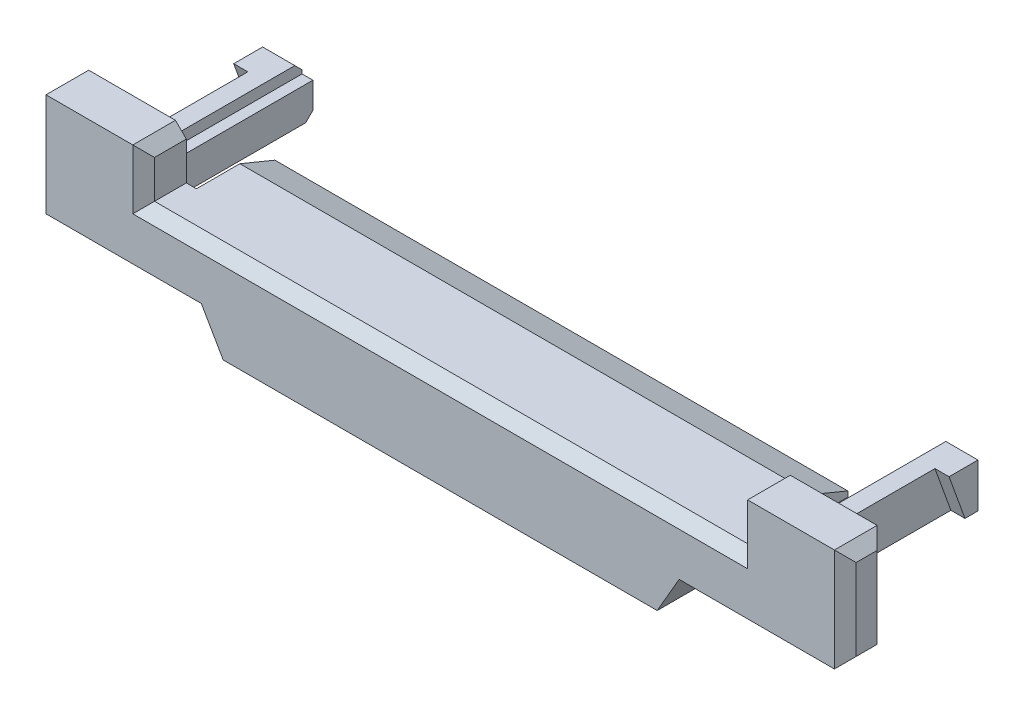
from build123d import *

# Parameters (mm, degrees)
BOSS_EXTRUDE1_DEPTH     = 1.18
SKETCH2_W               = 15.84
SKETCH2_H               = 2.17
BOSS_EXTRUDE2_DEPTH     = 0.55
CUT_EXTRUDE1_DEPTH      = 4.28
CUT_EXTRUDE1_DEPTH_BACK = 20.12
CHAMFER1_SIZE           = 0.3
CHAMFER2_SIZE           = 0.3
SKETCH4_W               = 1.19
SKETCH4_H               = 1.22
BOSS_EXTRUDE3_DEPTH     = 4
SKETCH5_W               = 0.3
SKETCH5_H               = 0.3
CUT_EXTRUDE2_DEPTH      = 4
CHAMFER3_SIZE           = 0.2
CUT_EXTRUDE3_DEPTH      = 0.39


with BuildPart() as part:
    # Sketch1 → Boss-Extrude1 (new body)
    with BuildSketch(Plane.XY):
        Polygon((-8.2, 0.6), (-8.2, 1.95), (-11.2, 1.95), (-11.2, -0.9), (-6.606217783, -0.9), (-6, -1.95), (6, -1.95), (6.606217783, -0.9), (11.2, -0.9), (11.2, 1.95), (8.2, 1.95), (8.2, 0.6), align=None)
    extrude(amount=BOSS_EXTRUDE1_DEPTH)

    # Sketch2 → Boss-Extrude2 (add)
    with BuildSketch(Plane(origin=(0, 0.6, 0), x_dir=(1, 0, 0), z_dir=(0, 1, 0))):
        with Locations((0, 1.085)):
            Rectangle(SKETCH2_W, SKETCH2_H)
    extrude(amount=-BOSS_EXTRUDE2_DEPTH)

    # Sketch3 → Cut-Extrude1 (cut, two sides)
    with BuildSketch(Plane.ZY.offset(7.92)) as cut_extrude1_sk:
        Polygon((-1.2, 0.6), (-2.17, 0.2), (-2.17, 0.6), align=None)
    extrude(amount=CUT_EXTRUDE1_DEPTH, mode=Mode.SUBTRACT)
    extrude(cut_extrude1_sk.sketch, amount=-CUT_EXTRUDE1_DEPTH_BACK, mode=Mode.SUBTRACT)

    # Chamfer1
    chamfer1_edges = [part.edges().sort_by_distance(p)[0] for p in [
        (11.2, 0.525, 0),
        (-11.2, 0.525, 1.18),
        (-11.2, 0.525, 0),
        (11.2, 1.95, 0.59),
        (11.2, -0.9, 0.59),
        (-11.2, -0.9, 0.59),
        (-11.2, 1.95, 0.59),
        (11.2, 0.525, 1.18),
    ]]
    chamfer(chamfer1_edges, length=CHAMFER1_SIZE)

    # Chamfer2
    chamfer2_edges = [part.edges().sort_by_distance(p)[0] for p in [
        (8.2, 1.95, 0.59),
        (-8.2, 1.95, 0.59),
        (8.2, 1.275, 1.18),
        (0, 0.6, 1.18),
        (-8.2, 1.275, 1.18),
    ]]
    chamfer(chamfer2_edges, length=CHAMFER2_SIZE)


with BuildPart() as body_2:
    # Sketch4 → Boss-Extrude3 (new body)
    with BuildSketch(Plane(origin=(0, 0, 0), x_dir=(-1, 0, 0), z_dir=(0, 0, -1))):
        with Locations((-9.295, 0.5)):
            Rectangle(SKETCH4_W, SKETCH4_H)
    extrude(amount=BOSS_EXTRUDE3_DEPTH)

    # Sketch5 → Cut-Extrude2 (cut)
    with BuildSketch(Plane(origin=(0, 0, -4), x_dir=(-1, 0, 0), z_dir=(0, 0, -1))):
        with Locations((-8.85, 0.96)):
            Rectangle(SKETCH5_W, SKETCH5_H)
    extrude(amount=-CUT_EXTRUDE2_DEPTH, mode=Mode.SUBTRACT)

    # Chamfer3
    chamfer3_edges = [body_2.edges().sort_by_distance(p)[0] for p in [
        (9.89, 0.5, -4),
        (9.295, -0.11, -4),
        (9.445, 1.11, -4),
    ]]
    chamfer(chamfer3_edges, length=CHAMFER3_SIZE)

    # Sketch6 → Cut-Extrude3 (cut)
    with BuildSketch(Plane(origin=(9.89, 0, 0), x_dir=(0, 0, -1), z_dir=(1, 0, 0))):
        Polygon((3.44, -0.11), (3, 1.11), (0, 1.11), (0, -0.11), align=None)
    extrude(amount=-CUT_EXTRUDE3_DEPTH, mode=Mode.SUBTRACT)


with BuildPart() as body_3:
    # Mirror1: mirrored copy
    add(body_2.part.mirror(Plane(origin=(0, 0, 0), x_dir=(0, 0, 1), z_dir=(1, 0, 0))))


solid = Compound([part.part, body_2.part, body_3.part])
